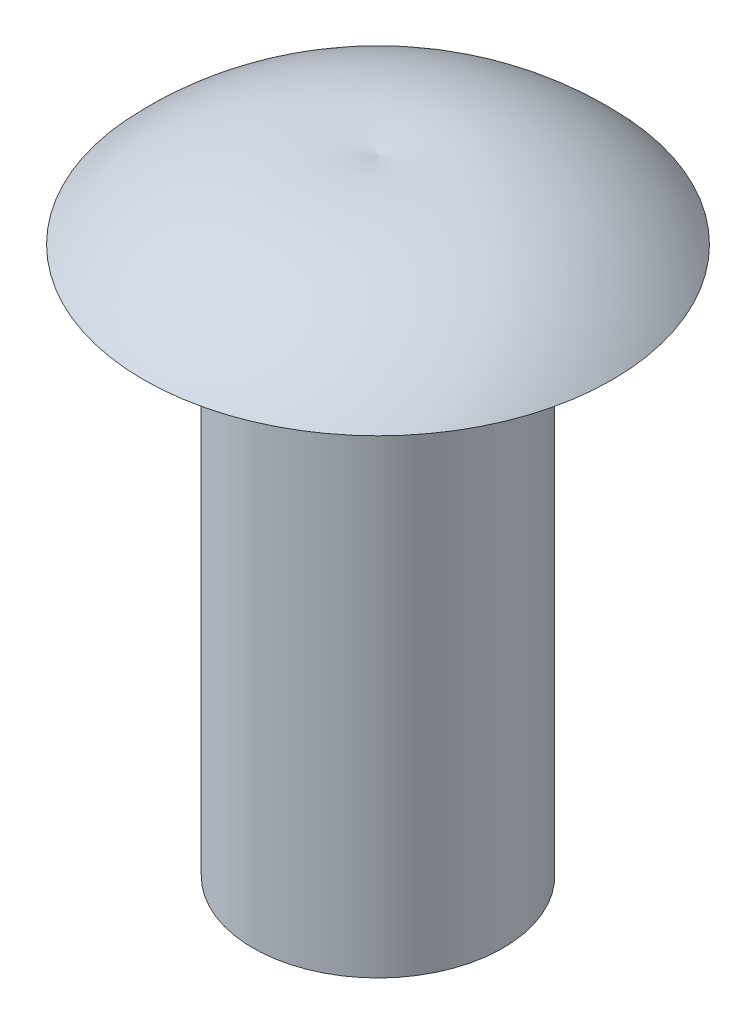
from build123d import *

# Parameters (mm, degrees)
SCALE1_SCALE = 1.21


with BuildPart() as part:
    # Sketch1 → Revolve1 (revolve)
    with BuildSketch(Plane.XY):
        with BuildLine():
            Line((0, 0), (2.032, 0))
            Line((2.032, 0), (2.032, 8.89))
            Line((2.032, 8.89), (3.81, 8.89))
            ThreePointArc((3.81, 8.89), (2.064894198, 10.004682594), (0, 10.16))
            Line((0, 10.16), (0, 0))
        make_face()
    revolve(axis=Axis((0, 0, 0), (0, 1, 0)))


with BuildPart() as part_1:
    # Scale1: scaled about (0, 5.627892311, 0)
    add(part.part.scale(SCALE1_SCALE).moved(Location((0, -1.181857385, 0))))


solid = part_1.part
